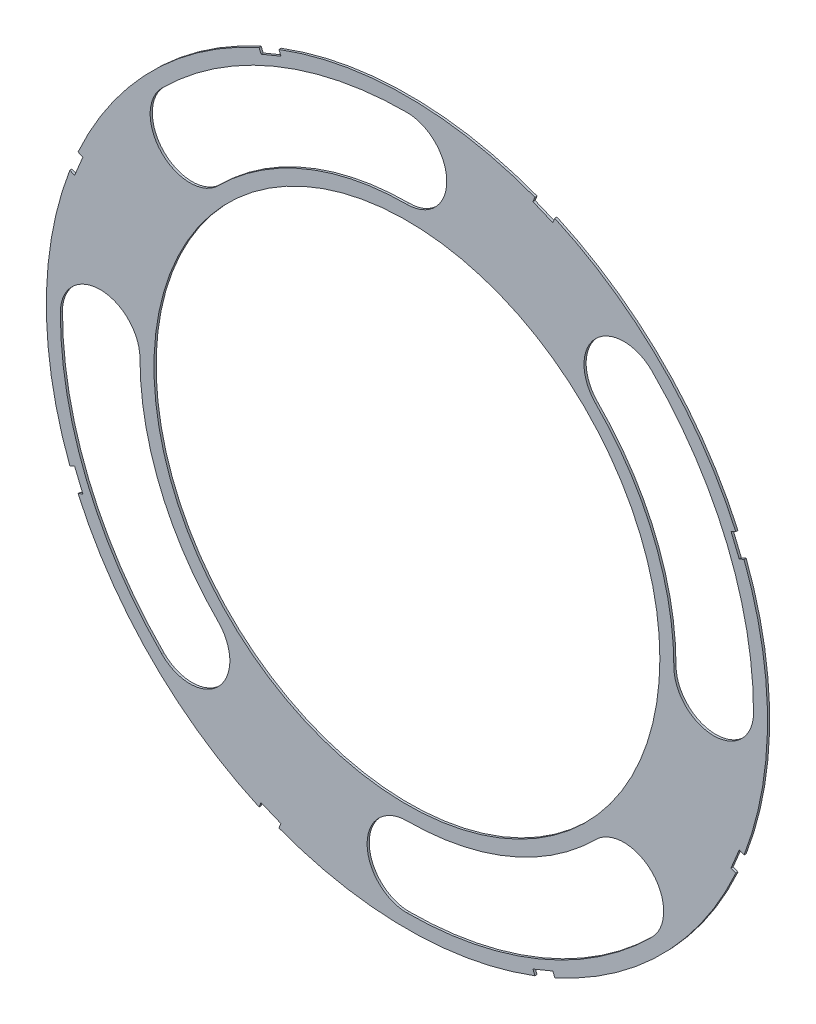
from build123d import *

# Parameters (mm, degrees)
SKETCH4_R           = 42.545
BOSS_EXTRUDE2_DEPTH = 0.254
SKETCH5_R           = 29.845
CUT_EXTRUDE5_DEPTH  = 1.254
CUT_EXTRUDE6_DEPTH  = 1.254
CUT_EXTRUDE11_DEPTH = 1.254


with BuildPart() as part:
    # Sketch4 → Boss-Extrude2 (new body)
    with BuildSketch(Plane.XY):
        Circle(SKETCH4_R)
    extrude(amount=BOSS_EXTRUDE2_DEPTH)

    # Sketch5 → Cut-Extrude5 (cut, through all)
    with BuildSketch(Plane.XY.offset(0.254)):
        Circle(SKETCH5_R)
    extrude(amount=-CUT_EXTRUDE5_DEPTH, mode=Mode.SUBTRACT)

    # Sketch6 → Cut-Extrude6 (cut, through all)
    with BuildSketch(Plane.XY.offset(0.254)):
        with BuildLine():
            ThreePointArc((28.916424965, 28.916424455), (22.27103521, 28.916424739), (22.271035377, 22.271034984))
            ThreePointArc((22.271035377, 22.271034984), (29.098509704, 12.052997511), (31.496, 5.5e-07))
            ThreePointArc((31.496, 5.5e-07), (36.195000082, -4.699), (40.894, 7.14e-07))
            ThreePointArc((40.894, 7.14e-07), (37.781129535, 15.649456446), (28.916424965, 28.916424455))
        make_face()
        with BuildLine():
            ThreePointArc((28.916424455, -28.916424965), (28.916424739, -22.27103521), (22.271034984, -22.271035377))
            ThreePointArc((22.271034984, -22.271035377), (12.052997511, -29.098509704), (5.5e-07, -31.496))
            ThreePointArc((5.5e-07, -31.496), (-4.699, -36.195000082), (7.14e-07, -40.894))
            ThreePointArc((7.14e-07, -40.894), (15.649456446, -37.781129535), (28.916424455, -28.916424965))
        make_face()
        with BuildLine():
            ThreePointArc((-28.916424965, -28.916424455), (-22.27103521, -28.916424739), (-22.271035377, -22.271034984))
            ThreePointArc((-22.271035377, -22.271034984), (-29.098509704, -12.052997511), (-31.496, -5.5e-07))
            ThreePointArc((-31.496, -5.5e-07), (-36.195000082, 4.699), (-40.894, -7.14e-07))
            ThreePointArc((-40.894, -7.14e-07), (-37.781129535, -15.649456446), (-28.916424965, -28.916424455))
        make_face()
        with BuildLine():
            ThreePointArc((-28.916424455, 28.916424965), (-28.916424739, 22.27103521), (-22.271034984, 22.271035377))
            ThreePointArc((-22.271034984, 22.271035377), (-12.052997511, 29.098509704), (-5.5e-07, 31.496))
            ThreePointArc((-5.5e-07, 31.496), (4.699, 36.195000082), (-7.14e-07, 40.894))
            ThreePointArc((-7.14e-07, 40.894), (-15.649456446, 37.781129535), (-28.916424455, 28.916424965))
        make_face()
    extrude(amount=-CUT_EXTRUDE6_DEPTH, mode=Mode.SUBTRACT)

    # Sketch8 → Cut-Extrude11 (cut, through all)
    with BuildSketch(Plane.XY.offset(0.254)):
        Polygon((40.379126173, 15.350943603), (39.407110255, 17.697597616), (38.233783248, 17.211589657), (39.205799167, 14.864935644), align=None)
        Polygon((-15.350943603, 40.379126173), (-17.697597616, 39.407110255), (-17.211589657, 38.233783248), (-14.864935644, 39.205799167), align=None)
        Polygon((-39.407110255, 17.697597616), (-40.379126173, 15.350943603), (-39.205799167, 14.864935644), (-38.233783248, 17.211589657), align=None)
        Polygon((-40.379126173, -15.350943603), (-39.407110255, -17.697597616), (-38.233783248, -17.211589657), (-39.205799167, -14.864935644), align=None)
        Polygon((-17.697597616, -39.407110255), (-15.350943603, -40.379126173), (-14.864935644, -39.205799167), (-17.211589657, -38.233783248), align=None)
        Polygon((15.350943603, -40.379126173), (17.697597616, -39.407110255), (17.211589657, -38.233783248), (14.864935644, -39.205799167), align=None)
        Polygon((39.407110255, -17.697597616), (40.379126173, -15.350943603), (39.205799167, -14.864935644), (38.233783248, -17.211589657), align=None)
        Polygon((17.697597616, 39.407110255), (15.350943603, 40.379126173), (14.864935644, 39.205799167), (17.211589657, 38.233783248), align=None)
    extrude(amount=-CUT_EXTRUDE11_DEPTH, mode=Mode.SUBTRACT)


solid = part.part
